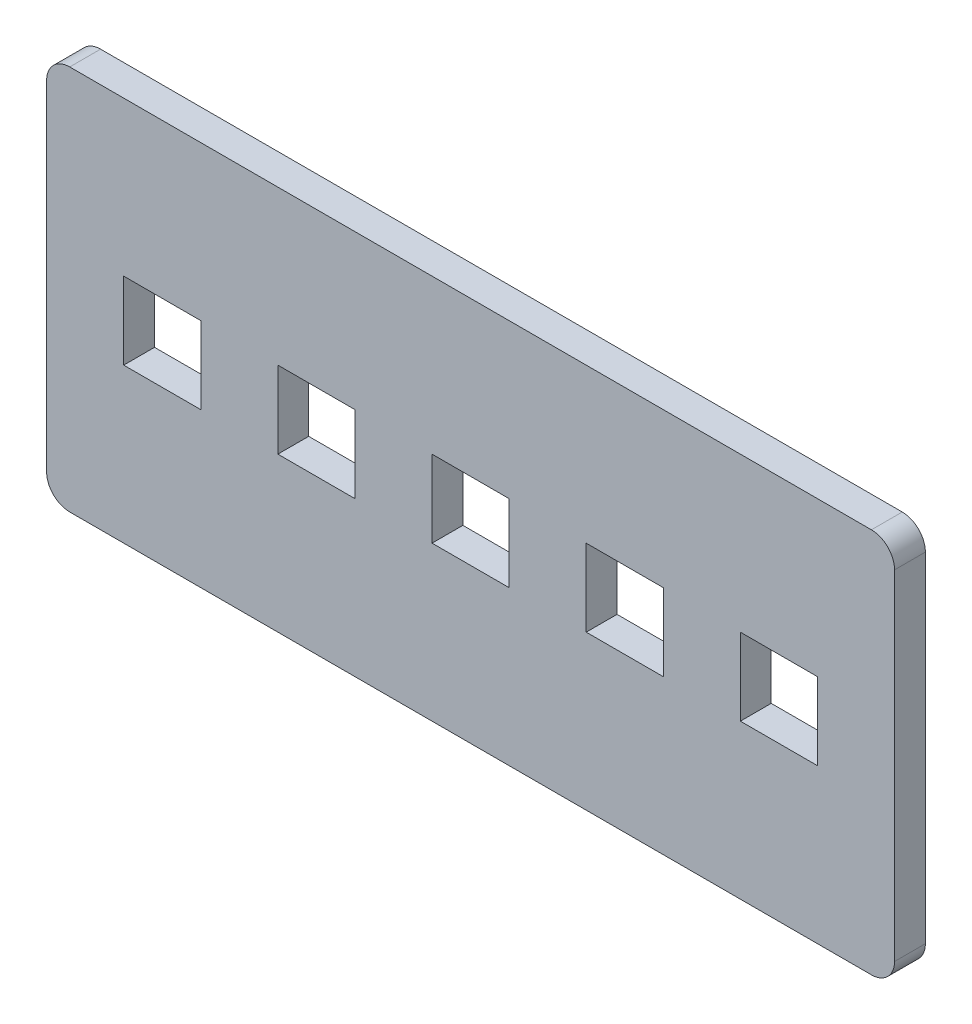
from build123d import *

# Parameters (mm, degrees)
ESQUISSE1_W        = 110
ESQUISSE1_H        = 50
ESQUISSE1_W_2      = 10
ESQUISSE1_H_2      = 10
BOSS_EXTRU_1_DEPTH = 4
CONG_1_R           = 3


with BuildPart() as part:
    # Esquisse1 → Boss.-Extru.1 (new body)
    with BuildSketch(Plane.XY):
        Rectangle(ESQUISSE1_W, ESQUISSE1_H)
        with Locations((-20, 0)):
            Rectangle(ESQUISSE1_W_2, ESQUISSE1_H_2, mode=Mode.SUBTRACT)
        with Locations((-40, 0)):
            Rectangle(ESQUISSE1_W_2, ESQUISSE1_H_2, mode=Mode.SUBTRACT)
        Rectangle(ESQUISSE1_W_2, ESQUISSE1_H_2, mode=Mode.SUBTRACT)
        with Locations((20, 0)):
            Rectangle(ESQUISSE1_W_2, ESQUISSE1_H_2, mode=Mode.SUBTRACT)
        with Locations((40, 0)):
            Rectangle(ESQUISSE1_W_2, ESQUISSE1_H_2, mode=Mode.SUBTRACT)
    extrude(amount=BOSS_EXTRU_1_DEPTH)

    # Congé1
    cong_1_edges = [part.edges().sort_by_distance(p)[0] for p in [
        (55, 25, 2),
        (55, -25, 2),
        (-55, -25, 2),
        (-55, 25, 2),
    ]]
    fillet(cong_1_edges, radius=CONG_1_R)


solid = part.part
